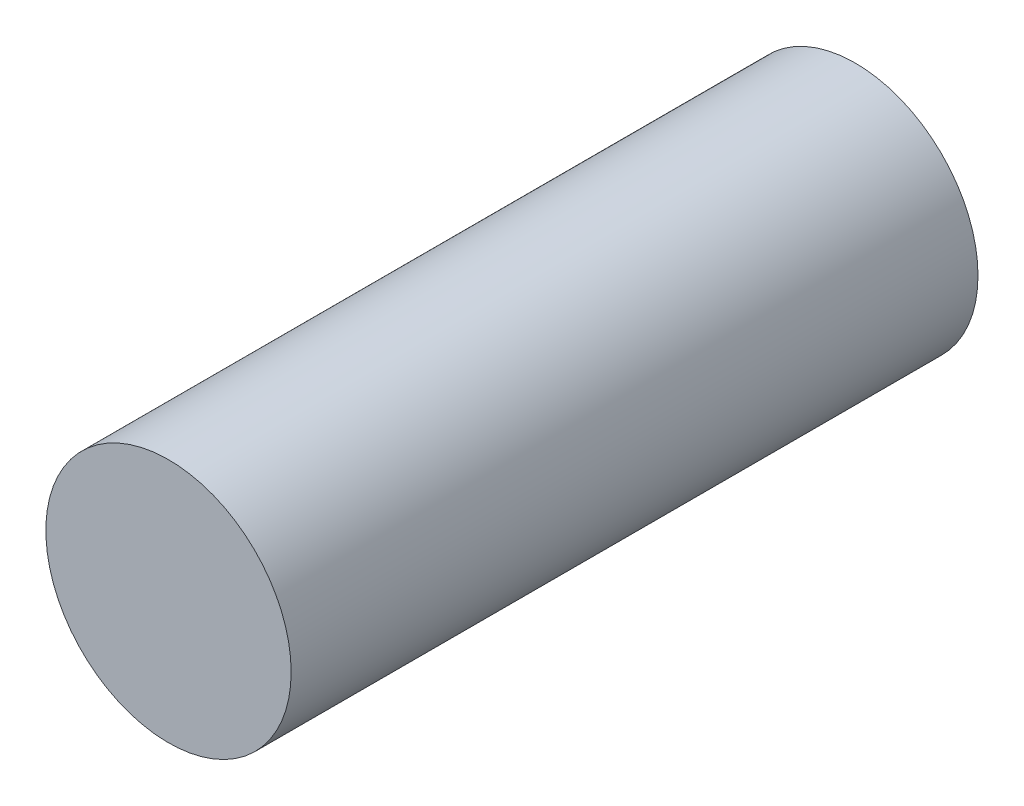
from build123d import *

# Parameters (mm, degrees)
SKETCH1_R           = 12.5
BOSS_EXTRUDE1_DEPTH = 70


with BuildPart() as part:
    # Sketch1 → Boss-Extrude1 (new body)
    with BuildSketch(Plane.XY):
        Circle(SKETCH1_R)
    extrude(amount=BOSS_EXTRUDE1_DEPTH)


solid = part.part
